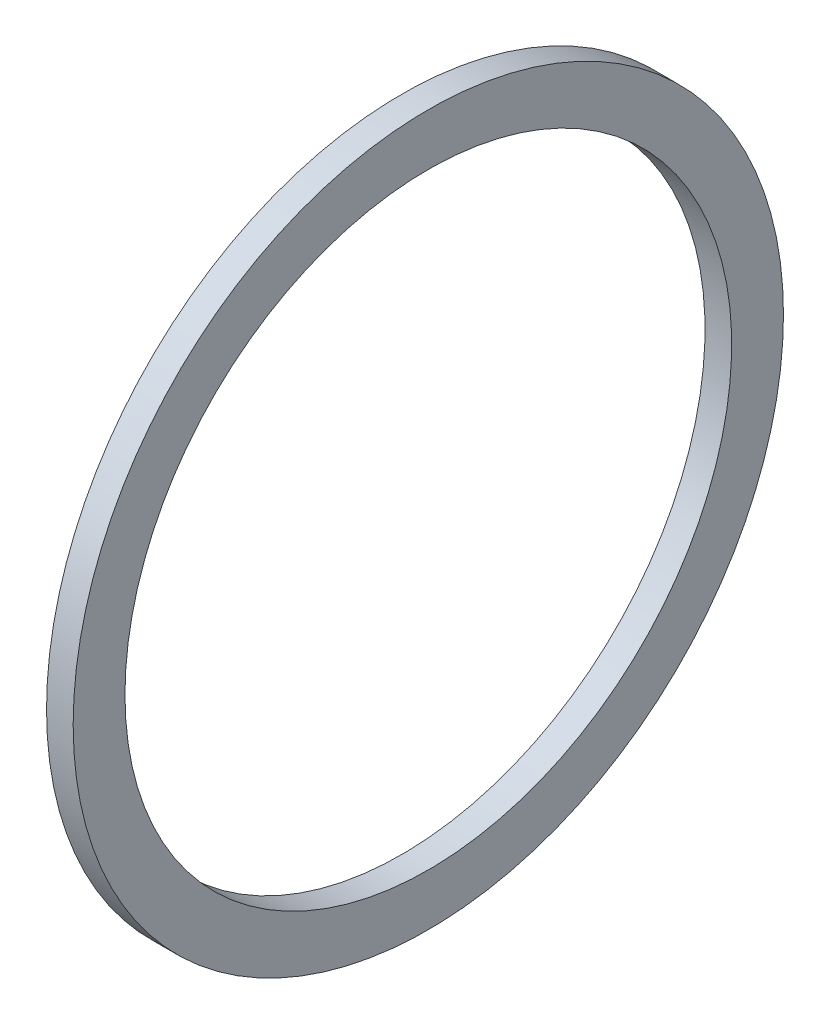
from build123d import *

# Parameters (mm, degrees)
SKETCH1_W = 9
SKETCH1_H = 17.5


with BuildPart() as part:
    # Sketch1 → Revolve1 (revolve)
    with BuildSketch(Plane.XY):
        with Locations((0, 111.25)):
            Rectangle(SKETCH1_W, SKETCH1_H)
    revolve(axis=Axis((0, 0, 0), (1, 0, 0)))


solid = part.part
